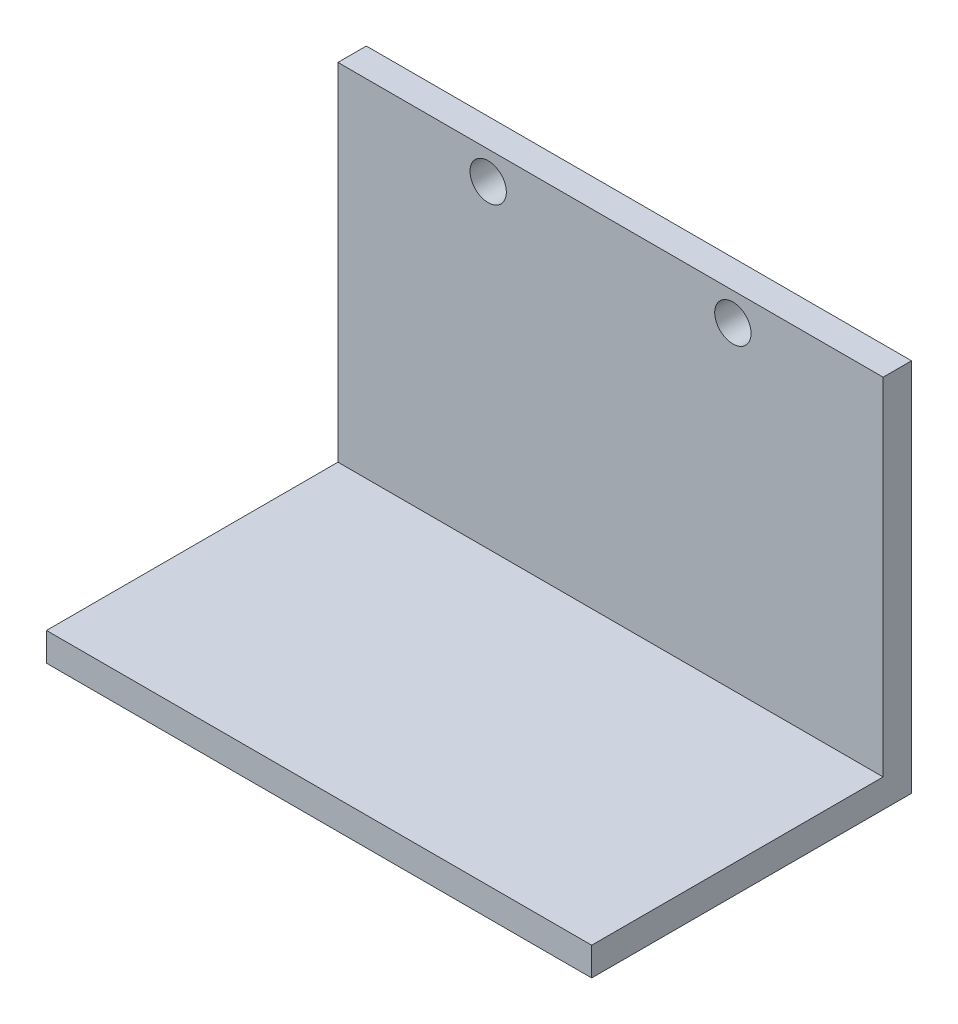
from build123d import *

# Parameters (mm, degrees)
EXTRUDE_THIN1_DEPTH   = 60
ESBO_O1_R             = 2
CORTE_EXTRUS_O1_DEPTH = 10


with BuildPart() as part:
    # Sketch1 → Extrude-Thin1 (new body)
    with BuildSketch(Plane(origin=(0, 0, 0), x_dir=(0, 0, -1), z_dir=(1, 0, 0))):
        Polygon((0, 0), (32.072996578, 0), (32.072996578, 38.1), (35.197996578, 38.1), (35.197996578, -3.125), (0, -3.125), align=None)
    extrude(amount=EXTRUDE_THIN1_DEPTH)

    # Esboço1 → Corte-extrusão1 (cut)
    with BuildSketch(Plane.XY.offset(-32.072996578)):
        with Locations((16.535273903, 35)):
            Circle(ESBO_O1_R)
        with Locations((43.464726097, 35)):
            Circle(ESBO_O1_R)
    extrude(amount=-CORTE_EXTRUS_O1_DEPTH, mode=Mode.SUBTRACT)


solid = part.part
